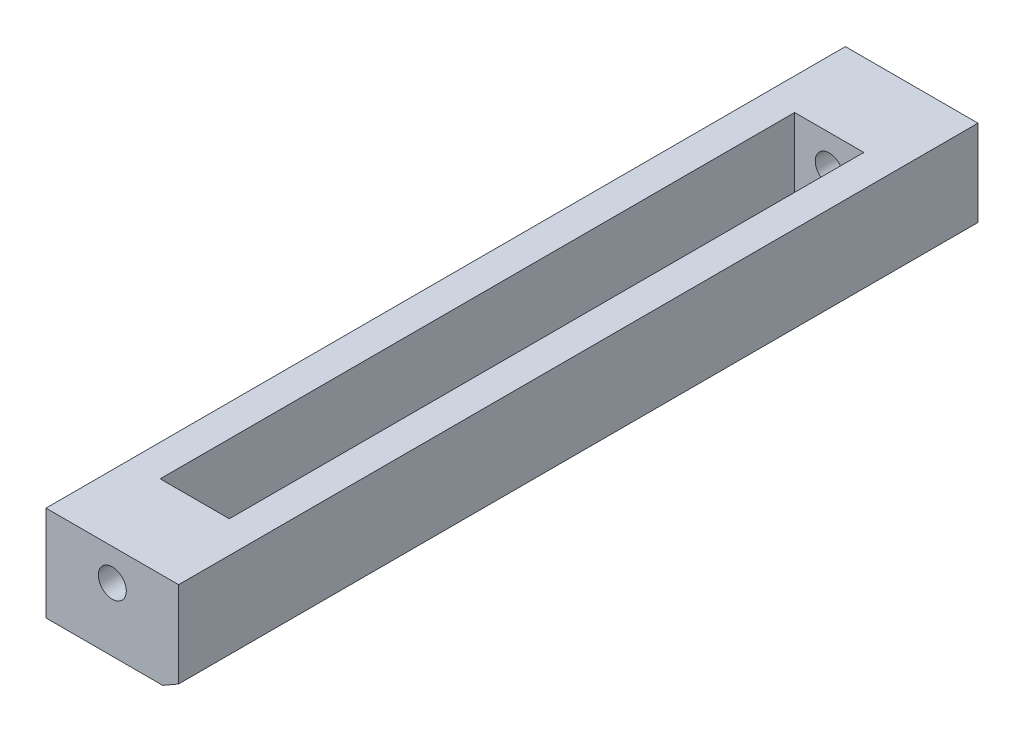
from build123d import *

# Parameters (mm, degrees)
SKETCH1_W                = 13.2715
SKETCH1_H                = 80.00000002
SKETCH1_W_2              = 6.9215
SKETCH1_H_2              = 63.5
BOSS_EXTRUDE1_DEPTH      = 3.175
BOSS_EXTRUDE1_DEPTH_BACK = 6.35
SKETCH4_R                = 1.399999994
CUT_EXTRUDE1_DEPTH       = 81.00000002
CHAMFER1_SIZE            = 1.5875
CHAMFER1_SIZE2           = 0.916543552


with BuildPart() as part:
    # Sketch1 → Boss-Extrude1 (new body, two sides)
    with BuildSketch(Plane(origin=(0, 0, 0), x_dir=(1, 0, 0), z_dir=(0, 1, 0))) as boss_extrude1_sk:
        Rectangle(SKETCH1_W, SKETCH1_H)
        Rectangle(SKETCH1_W_2, SKETCH1_H_2, mode=Mode.SUBTRACT)
    extrude(amount=BOSS_EXTRUDE1_DEPTH)
    extrude(boss_extrude1_sk.sketch, amount=-BOSS_EXTRUDE1_DEPTH_BACK)

    # Sketch4 → Cut-Extrude1 (cut, through all)
    with BuildSketch(Plane.XY.offset(40.00000001)):
        Circle(SKETCH4_R)
    extrude(amount=-CUT_EXTRUDE1_DEPTH, mode=Mode.SUBTRACT)

    # Chamfer1
    chamfer1_edges = [part.edges().sort_by_distance(p)[0] for p in [
        (6.63575, -6.35, 0),
    ]]
    chamfer1_side = [part.faces().sort_by_distance(p)[0] for p in [
        (0, -6.35, 39.18906643),
    ]]
    chamfer(chamfer1_edges, length=CHAMFER1_SIZE, length2=CHAMFER1_SIZE2, reference=chamfer1_side[0])


solid = part.part
